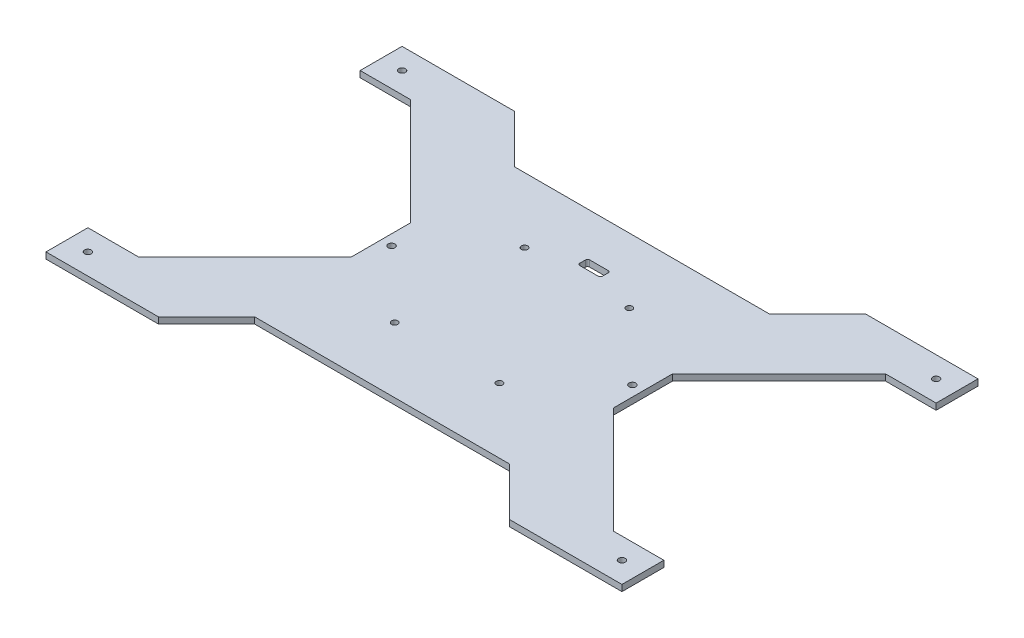
from build123d import *

# Parameters (mm, degrees)
SKETCH1_R          = 1.6
EXTRUDE2_DEPTH     = 3
CUT_EXTRUDE4_DEPTH = 3


with BuildPart() as part:
    # Sketch1 → Extrude2 (new body)
    with BuildSketch(Plane.XZ):
        Polygon((-21.510078765, -227.497048214), (2.632056859, -227.497048214), (53.489921235, -278.35491259), (53.489921235, -306.639183837), (2.632056859, -357.497048214), (-21.510078765, -357.497048214), (-21.510078765, -377.497048214), (32.129531542, -377.497048214), (55.092111961, -354.534467794), (176.887730509, -354.534467794), (199.850310928, -377.497048214), (253.489921235, -377.497048214), (253.489921235, -357.497048214), (229.347785611, -357.497048214), (178.489921235, -306.639183837), (178.489921235, -278.35491259), (229.347785611, -227.497048214), (253.489921235, -227.497048214), (253.489921235, -207.497048214), (199.850310928, -207.497048214), (176.887730509, -230.459628633), (55.092111961, -230.459628633), (32.129531542, -207.497048214), (-21.510078765, -207.497048214), align=None)
        with Locations((-11.510078765, -367.497048214)):
            Circle(SKETCH1_R, mode=Mode.SUBTRACT)
        with Locations((58.489921235, -292.497048214)):
            Circle(SKETCH1_R, mode=Mode.SUBTRACT)
        with Locations((243.489921235, -367.497048214)):
            Circle(SKETCH1_R, mode=Mode.SUBTRACT)
        with Locations((173.489921235, -292.497048214)):
            Circle(SKETCH1_R, mode=Mode.SUBTRACT)
        with Locations((-11.510078765, -217.497048214)):
            Circle(SKETCH1_R, mode=Mode.SUBTRACT)
        with Locations((243.489921235, -217.497048214)):
            Circle(SKETCH1_R, mode=Mode.SUBTRACT)
    extrude(amount=EXTRUDE2_DEPTH)

    # Sketch4 → Cut-Extrude4 (cut)
    with BuildSketch(Plane.XZ.offset(3)):
        with BuildLine():
            Line((121.389921235, -332.984350137), (121.389921235, -330.284350137))
            ThreePointArc((121.389921235, -330.284350137), (121.097028016, -329.577243356), (120.389921235, -329.284350137))
            Line((120.389921235, -329.284350137), (111.589921235, -329.284350137))
            ThreePointArc((111.589921235, -329.284350137), (110.882814454, -329.577243356), (110.589921235, -330.284350137))
            Line((110.589921235, -330.284350137), (110.589921235, -332.984350137))
            ThreePointArc((110.589921235, -332.984350137), (110.882814454, -333.691456918), (111.589921235, -333.984350137))
            Line((111.589921235, -333.984350137), (120.389921235, -333.984350137))
            ThreePointArc((120.389921235, -333.984350137), (121.097028016, -333.691456918), (121.389921235, -332.984350137))
        make_face()
        with BuildLine():
            ThreePointArc((142.489921235, -261.497048214), (140.989921235, -259.997048214), (139.489921235, -261.497048214))
            ThreePointArc((139.489921235, -261.497048214), (140.989921235, -262.997048214), (142.489921235, -261.497048214))
        make_face()
        with BuildLine():
            ThreePointArc((139.489921235, -323.497048214), (140.989921235, -324.997048214), (142.489921235, -323.497048214))
            ThreePointArc((142.489921235, -323.497048214), (140.989921235, -321.997048214), (139.489921235, -323.497048214))
        make_face()
        with BuildLine():
            ThreePointArc((92.489921235, -261.497048214), (90.989921235, -259.997048214), (89.489921235, -261.497048214))
            ThreePointArc((89.489921235, -261.497048214), (90.989921235, -262.997048214), (92.489921235, -261.497048214))
        make_face()
        with BuildLine():
            ThreePointArc((92.489921235, -323.497048214), (90.989921235, -321.997048214), (89.489921235, -323.497048214))
            ThreePointArc((89.489921235, -323.497048214), (90.989921235, -324.997048214), (92.489921235, -323.497048214))
        make_face()
    extrude(amount=-CUT_EXTRUDE4_DEPTH, mode=Mode.SUBTRACT)


solid = part.part
